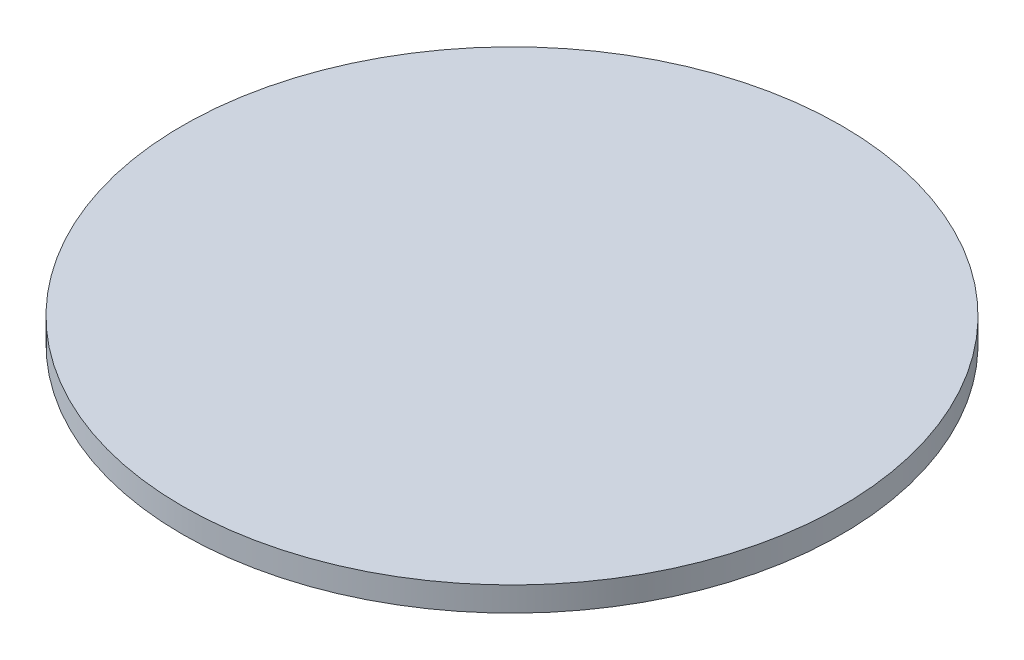
from build123d import *

# Parameters (mm, degrees)
SKETCH1_R           = 13.5
BOSS_EXTRUDE1_DEPTH = 1


with BuildPart() as part:
    # Sketch1 → Boss-Extrude1 (new body)
    with BuildSketch(Plane(origin=(0, 0, 0), x_dir=(1, 0, 0), z_dir=(0, 1, 0))):
        Circle(SKETCH1_R)
    extrude(amount=BOSS_EXTRUDE1_DEPTH)


solid = part.part
